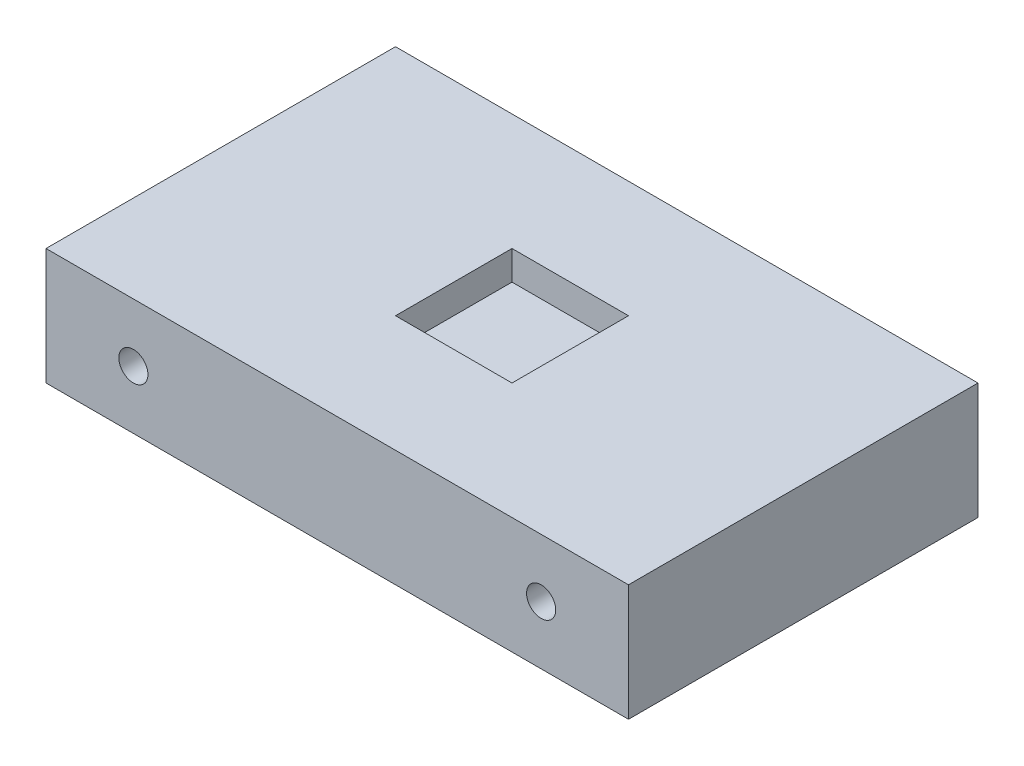
from build123d import *

# Parameters (mm, degrees)
SKETCH1_W           = 127
SKETCH1_H           = 25.4
BOSS_EXTRUDE1_DEPTH = 76.2
SKETCH2_R           = 3.175
CUT_EXTRUDE1_DEPTH  = 12.7
SKETCH3_R           = 3.175
CUT_EXTRUDE2_DEPTH  = 12.7
SKETCH4_W           = 25.4
SKETCH4_H           = 25.4
CUT_EXTRUDE3_DEPTH  = 6.35


with BuildPart() as part:
    # Sketch1 → Boss-Extrude1 (new body)
    with BuildSketch(Plane.XY):
        with Locations((63.5, 12.7)):
            Rectangle(SKETCH1_W, SKETCH1_H)
    extrude(amount=BOSS_EXTRUDE1_DEPTH)

    # Sketch2 → Cut-Extrude1 (cut)
    with BuildSketch(Plane.XY.offset(76.2)):
        with Locations((19.05, 12.7)):
            Circle(SKETCH2_R)
        with Locations((107.95, 12.7)):
            Circle(SKETCH2_R)
    extrude(amount=-CUT_EXTRUDE1_DEPTH, mode=Mode.SUBTRACT)

    # Sketch3 → Cut-Extrude2 (cut)
    with BuildSketch(Plane(origin=(0, 0, 0), x_dir=(-1, 0, 0), z_dir=(0, 0, -1))):
        with Locations((-107.95, 12.7)):
            Circle(SKETCH3_R)
        with Locations((-19.05, 12.7)):
            Circle(SKETCH3_R)
    extrude(amount=-CUT_EXTRUDE2_DEPTH, mode=Mode.SUBTRACT)

    # Sketch4 → Cut-Extrude3 (cut)
    with BuildSketch(Plane(origin=(0, 25.4, 0), x_dir=(1, 0, 0), z_dir=(0, 1, 0))):
        with Locations((63.5, -38.1)):
            Rectangle(SKETCH4_W, SKETCH4_H)
    extrude(amount=-CUT_EXTRUDE3_DEPTH, mode=Mode.SUBTRACT)


solid = part.part
